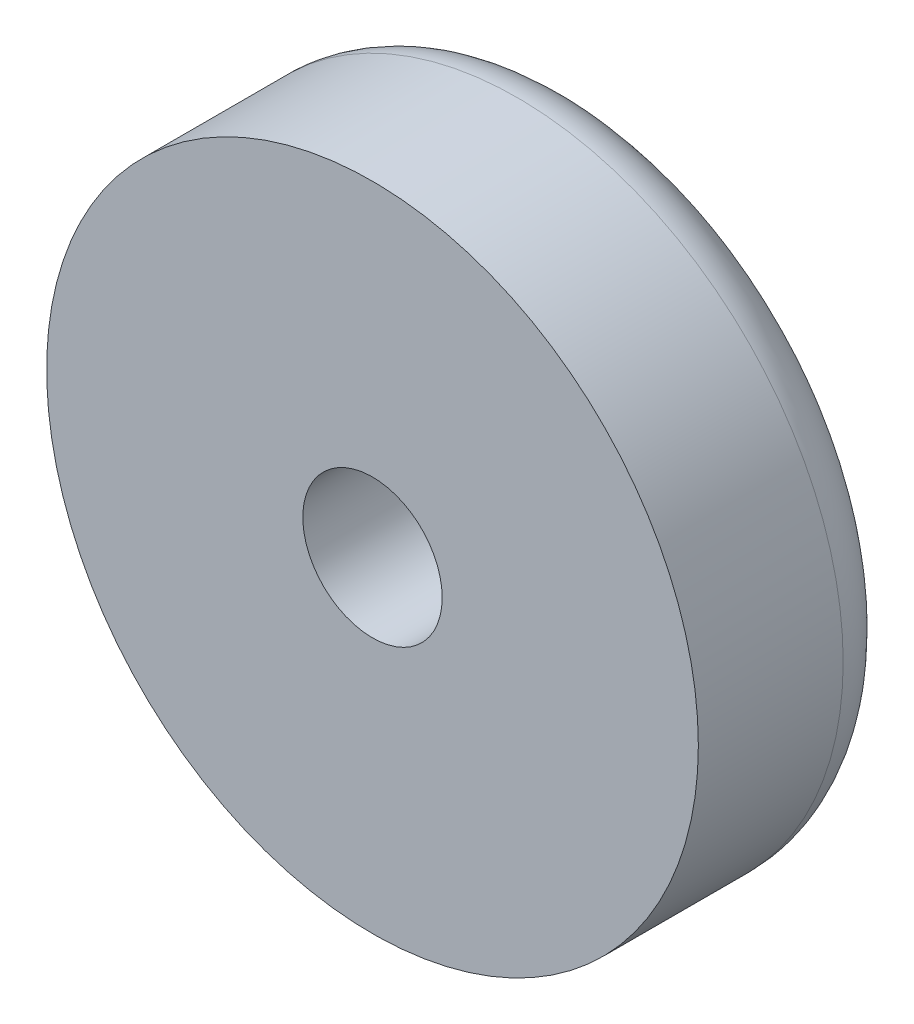
from build123d import *

# Parameters (mm, degrees)
SKETCH4_R           = 18
SKETCH4_R_2         = 3.85
BOSS_EXTRUDE1_DEPTH = 8


with BuildPart() as part:
    # Sketch3 → Revolve2 (revolve)
    with BuildSketch(Plane(origin=(0, 0, 0), x_dir=(1, 0, 0), z_dir=(0, 1, 0))):
        with BuildLine():
            Line((0, 3.160044373), (3.85, 3.160044373))
            Line((3.85, 3.160044373), (3.85, 0))
            Line((3.85, 0), (18, 0))
            ThreePointArc((18, 0), (15.779795897, 3.046309242), (12.2, 1.865475811))
            Line((12.2, 1.865475811), (12.2, 1.74))
            Line((12.2, 1.74), (11.7, 1.74))
            Line((11.7, 1.74), (11.7, 2.2))
            Line((11.7, 2.2), (5, 2.2))
            Line((5, 2.2), (5, 1.61598722))
            Line((5, 1.61598722), (4.3, 1.61598722))
            Line((4.3, 1.61598722), (4.3, 3.376031593))
            ThreePointArc((4.3, 3.376031593), (2.194964612, 4.036754088), (0, 4.260044373))
            Line((0, 4.260044373), (0, 3.160044373))
        make_face()
    revolve(axis=Axis((0, 0, 0), (0, 0, -1)))

    # Sketch4 → Boss-Extrude1 (add)
    with BuildSketch(Plane.XY):
        Circle(SKETCH4_R)
        Circle(SKETCH4_R_2, mode=Mode.SUBTRACT)
    extrude(amount=BOSS_EXTRUDE1_DEPTH)


solid = part.part
